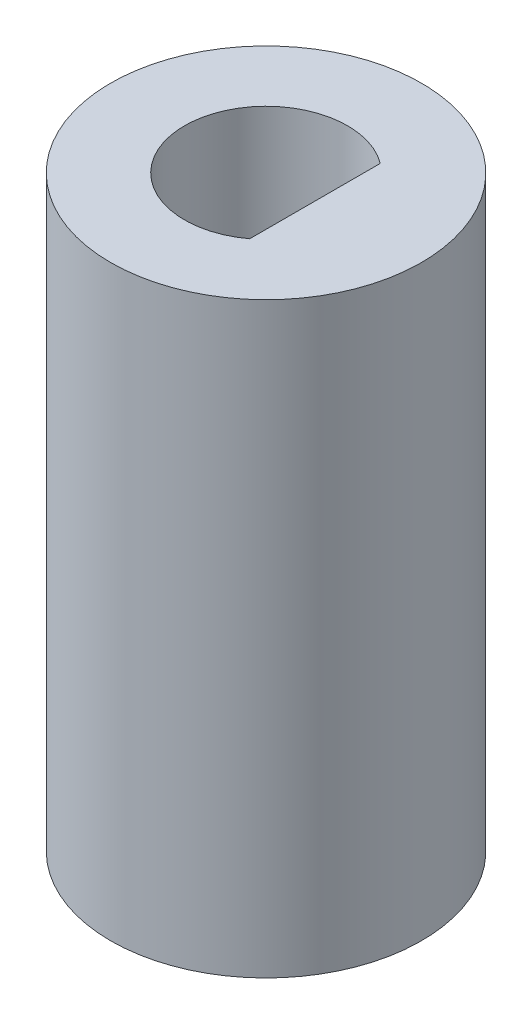
from build123d import *

# Parameters (mm, degrees)
BOSS_EXTRUDE1_DEPTH      = 9
BOSS_EXTRUDE1_DEPTH_BACK = 9
SKETCH1_R                = 4.7625
CUT_EXTRUDE1_DEPTH       = 7
SKETCH7_R                = 1.5875
CUT_EXTRUDE2_DEPTH       = 7


with BuildPart() as part:
    # Sketch1 → Boss-Extrude1 (new, two sides: drawn at the far end of the back side and taken through both)
    with BuildSketch(Plane(origin=(0, 0, 0), x_dir=(1, 0, 0), z_dir=(0, 1, 0)).offset(-BOSS_EXTRUDE1_DEPTH_BACK)):
        with Locations((-4.672198487, 0.923020882)):
            Circle(SKETCH1_R)
    extrude(amount=BOSS_EXTRUDE1_DEPTH + BOSS_EXTRUDE1_DEPTH_BACK)

    # Sketch6 → Cut-Extrude1 (cut)
    with BuildSketch(Plane(origin=(0, 9, 0), x_dir=(1, 0, 0), z_dir=(0, 1, 0))):
        with BuildLine():
            Line((-3.172198487, -1.076979118), (-3.172198487, 2.923020882))
            ThreePointArc((-3.172198487, 2.923020882), (-7.172198487, 0.923020882), (-3.172198487, -1.076979118))
        make_face()
    extrude(amount=-CUT_EXTRUDE1_DEPTH, mode=Mode.SUBTRACT)

    # Sketch7 → Cut-Extrude2 (cut)
    with BuildSketch(Plane.XZ.offset(9)):
        with Locations((-4.672198487, -0.923020882)):
            Circle(SKETCH7_R)
    extrude(amount=-CUT_EXTRUDE2_DEPTH, mode=Mode.SUBTRACT)


solid = part.part
